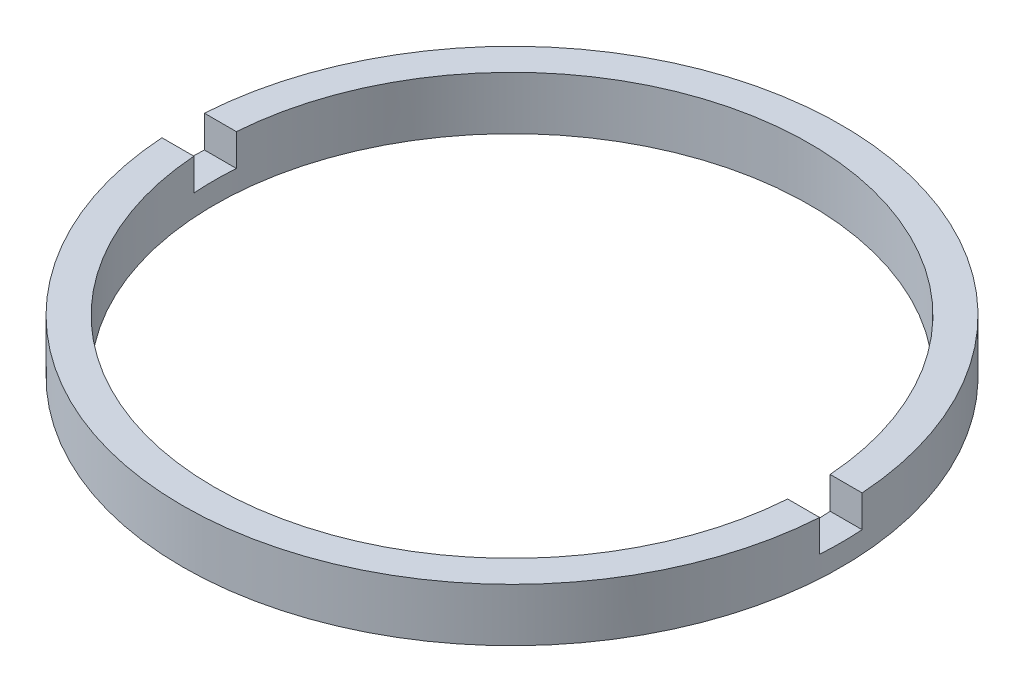
from build123d import *

# Parameters (mm, degrees)
SKETCH_1_W          = 1.5
SKETCH_1_H          = 2.5
SKETCH_2_W          = 53.705080546
SKETCH_2_H          = 2
CUT_EXTRUDE_1_DEPTH = 1.5


with BuildPart() as part:
    # 草图1 → 旋转1 (revolve)
    with BuildSketch(Plane.XY, mode=Mode.PRIVATE) as revolve_1_sk:
        with Locations((14.75, -3.214249787)):
            Rectangle(SKETCH_1_W, SKETCH_1_H)
    revolve(revolve_1_sk.sketch.rotate(Axis((0, 56.260842627, 0), (0, -1, 0)), 90), axis=Axis((0, 56.260842627, 0), (0, -1, 0)))  # turned: the seam where the file's is

    # 草图2 → 切除-拉伸1 (cut)
    with BuildSketch(Plane(origin=(0, -1.964249787, 0), x_dir=(1, 0, 0), z_dir=(0, 1, 0))):
        Rectangle(SKETCH_2_W, SKETCH_2_H)
    extrude(amount=-CUT_EXTRUDE_1_DEPTH, mode=Mode.SUBTRACT)


solid = part.part
